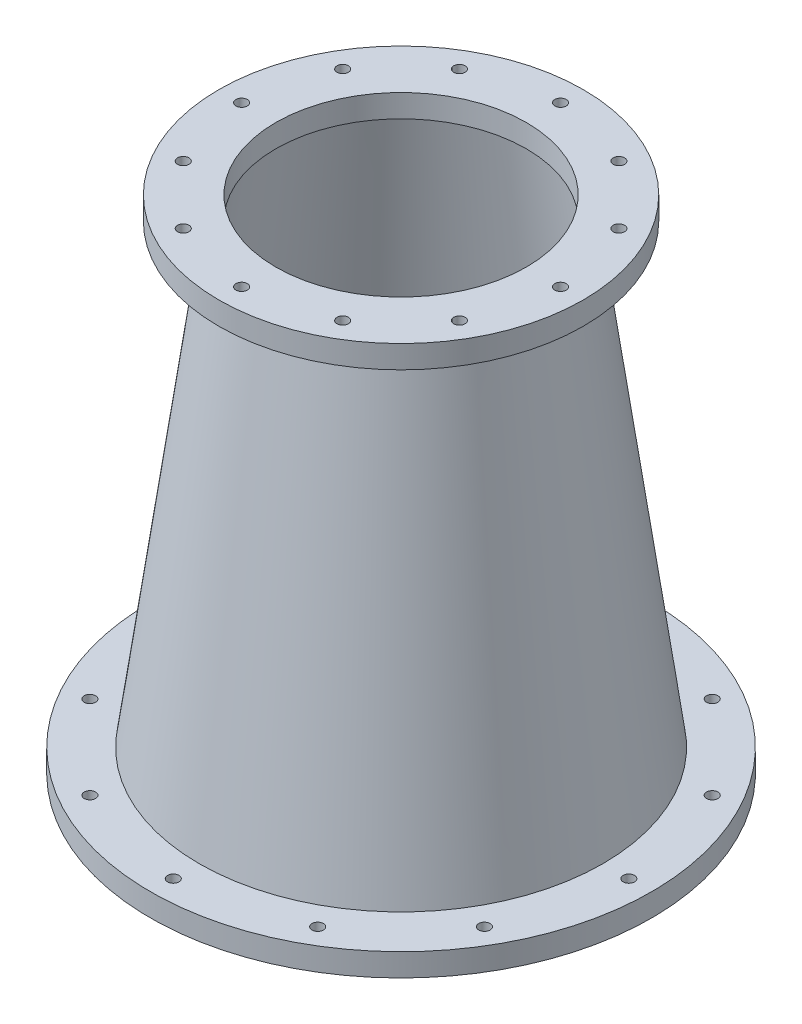
from build123d import *

# Parameters (mm, degrees)
SKETCH2_R           = 101.6
SKETCH2_R_2         = 69.85
SKETCH2_R_3         = 3.175
BOSS_EXTRUDE1_DEPTH = 12.7
SKETCH3_R           = 139.7
SKETCH3_R_2         = 107.95
SKETCH3_R_3         = 3.175
BOSS_EXTRUDE2_DEPTH = 12.7


with BuildPart() as part:
    # Sketch1 → Revolve1 (revolve)
    with BuildSketch(Plane.XY):
        Polygon((69.85, 279.4), (107.95, 0), (114.3, 0), (76.2, 279.4), align=None)
    revolve(axis=Axis((0, 279.4, 0), (0, -1, 0)))

    # Sketch2 → Boss-Extrude1 (add)
    with BuildSketch(Plane(origin=(0, 279.4, 0), x_dir=(1, 0, 0), z_dir=(0, 1, 0))):
        Circle(SKETCH2_R)
        Circle(SKETCH2_R_2, mode=Mode.SUBTRACT)
        with Locations((0, 88.9)):
            Circle(SKETCH2_R_3, mode=Mode.SUBTRACT)
        with Locations((44.45, 76.989658396)):
            Circle(SKETCH2_R_3, mode=Mode.SUBTRACT)
        with Locations((76.989658396, 44.45)):
            Circle(SKETCH2_R_3, mode=Mode.SUBTRACT)
        with Locations((88.9, 0)):
            Circle(SKETCH2_R_3, mode=Mode.SUBTRACT)
        with Locations((76.989658396, -44.45)):
            Circle(SKETCH2_R_3, mode=Mode.SUBTRACT)
        with Locations((44.45, -76.989658396)):
            Circle(SKETCH2_R_3, mode=Mode.SUBTRACT)
        with Locations((0, -88.9)):
            Circle(SKETCH2_R_3, mode=Mode.SUBTRACT)
        with Locations((-44.45, -76.989658396)):
            Circle(SKETCH2_R_3, mode=Mode.SUBTRACT)
        with Locations((-76.989658396, -44.45)):
            Circle(SKETCH2_R_3, mode=Mode.SUBTRACT)
        with Locations((-88.9, 0)):
            Circle(SKETCH2_R_3, mode=Mode.SUBTRACT)
        with Locations((-76.989658396, 44.45)):
            Circle(SKETCH2_R_3, mode=Mode.SUBTRACT)
        with Locations((-44.45, 76.989658396)):
            Circle(SKETCH2_R_3, mode=Mode.SUBTRACT)
    extrude(amount=-BOSS_EXTRUDE1_DEPTH)

    # Sketch3 → Boss-Extrude2 (add)
    with BuildSketch(Plane(origin=(0, 0, 0), x_dir=(-1, 0, 0), z_dir=(0, -1, 0))):
        Circle(SKETCH3_R)
        Circle(SKETCH3_R_2, mode=Mode.SUBTRACT)
        with Locations((0, 127)):
            Circle(SKETCH3_R_3, mode=Mode.SUBTRACT)
        with Locations((63.5, 109.985226281)):
            Circle(SKETCH3_R_3, mode=Mode.SUBTRACT)
        with Locations((109.985226281, 63.5)):
            Circle(SKETCH3_R_3, mode=Mode.SUBTRACT)
        with Locations((127, 0)):
            Circle(SKETCH3_R_3, mode=Mode.SUBTRACT)
        with Locations((109.985226281, -63.5)):
            Circle(SKETCH3_R_3, mode=Mode.SUBTRACT)
        with Locations((63.5, -109.985226281)):
            Circle(SKETCH3_R_3, mode=Mode.SUBTRACT)
        with Locations((0, -127)):
            Circle(SKETCH3_R_3, mode=Mode.SUBTRACT)
        with Locations((-63.5, -109.985226281)):
            Circle(SKETCH3_R_3, mode=Mode.SUBTRACT)
        with Locations((-109.985226281, -63.5)):
            Circle(SKETCH3_R_3, mode=Mode.SUBTRACT)
        with Locations((-127, 0)):
            Circle(SKETCH3_R_3, mode=Mode.SUBTRACT)
        with Locations((-109.985226281, 63.5)):
            Circle(SKETCH3_R_3, mode=Mode.SUBTRACT)
        with Locations((-63.5, 109.985226281)):
            Circle(SKETCH3_R_3, mode=Mode.SUBTRACT)
    extrude(amount=-BOSS_EXTRUDE2_DEPTH)


solid = part.part
